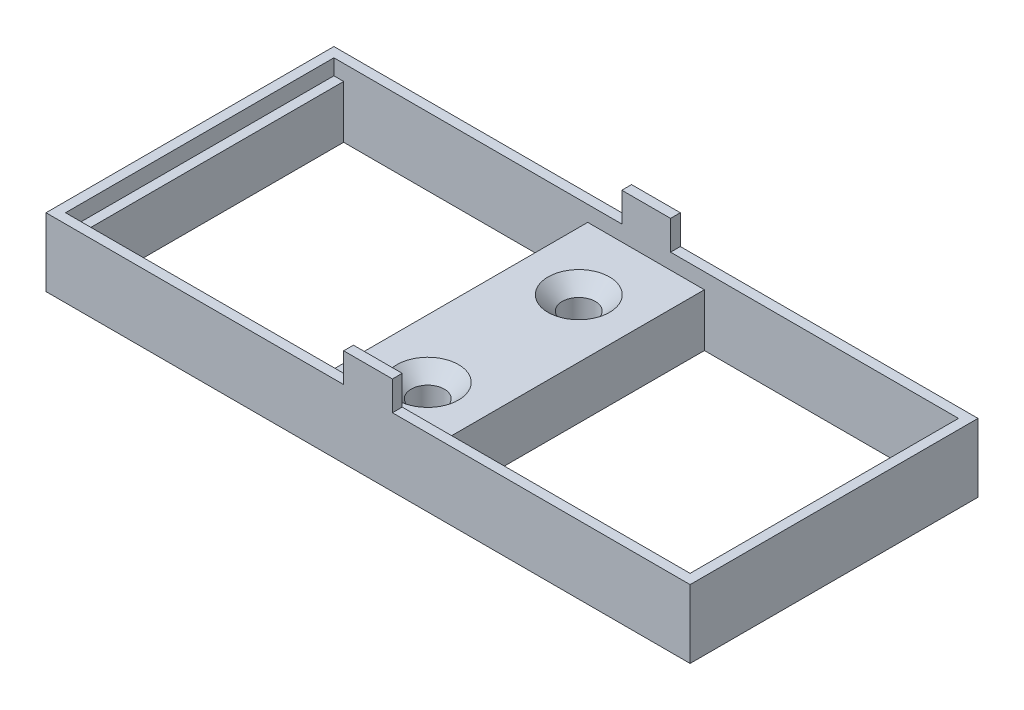
from build123d import *

# Parameters (mm, degrees)
SKETCH1_W                                           = 66
SKETCH1_H                                           = 29.5
BOSS_EXTRUDE1_DEPTH                                 = 7
SKETCH18_W                                          = 5
SKETCH18_H                                          = 1
BOSS_EXTRUDE3_DEPTH                                 = 3
SKETCH2_W                                           = 64
SKETCH2_H                                           = 27.5
CUT_EXTRUDE1_DEPTH                                  = 1.6
SKETCH19_W                                          = 25.008900438
SKETCH19_H                                          = 27.5
SKETCH19_W_2                                        = 25.033550957
CUT_EXTRUDE3_DEPTH                                  = 10
CSK_FOR_M3_COUNTERSUNK_FLAT_HEAD_SCREW2_D           = 3.4
CSK_FOR_M3_COUNTERSUNK_FLAT_HEAD_SCREW2_CSINK_D     = 6.3
CSK_FOR_M3_COUNTERSUNK_FLAT_HEAD_SCREW2_CSINK_ANGLE = 90


with BuildPart() as part:
    # Sketch1 → Boss-Extrude1 (new body)
    with BuildSketch(Plane(origin=(0, 0, 0), x_dir=(1, 0, 0), z_dir=(0, 1, 0))):
        with Locations((33, -14.75)):
            Rectangle(SKETCH1_W, SKETCH1_H)
    extrude(amount=BOSS_EXTRUDE1_DEPTH)

    # Sketch18 → Boss-Extrude3 (add)
    with BuildSketch(Plane(origin=(0, 7, 0), x_dir=(1, 0, 0), z_dir=(0, 1, 0))):
        with Locations((33, -0.5)):
            Rectangle(SKETCH18_W, SKETCH18_H)
        with Locations((33, -29)):
            Rectangle(SKETCH18_W, SKETCH18_H)
    extrude(amount=BOSS_EXTRUDE3_DEPTH)

    # Sketch2 → Cut-Extrude1 (cut)
    with BuildSketch(Plane(origin=(0, 7, 0), x_dir=(1, 0, 0), z_dir=(0, 1, 0))):
        with Locations((33, -14.75)):
            Rectangle(SKETCH2_W, SKETCH2_H)
    extrude(amount=-CUT_EXTRUDE1_DEPTH, mode=Mode.SUBTRACT)

    # Sketch19 → Cut-Extrude3 (cut)
    with BuildSketch(Plane(origin=(0, 5.4, 0), x_dir=(1, 0, 0), z_dir=(0, 1, 0))):
        with Locations((14.504450219, -14.75)):
            Rectangle(SKETCH19_W, SKETCH19_H)
        with Locations((51.483224522, -14.75)):
            Rectangle(SKETCH19_W_2, SKETCH19_H)
    extrude(amount=-CUT_EXTRUDE3_DEPTH, mode=Mode.SUBTRACT)

    # CSK for M3 Countersunk Flat Head Screw2 (through all)
    with Locations(Plane(origin=(32.966449043, 5.4, 7.875), x_dir=(0, 0, 1), z_dir=(0, 1, 0))):
        with Locations((0, 0), (15.515633601, 0.042451395)):
            CounterSinkHole(CSK_FOR_M3_COUNTERSUNK_FLAT_HEAD_SCREW2_D / 2, CSK_FOR_M3_COUNTERSUNK_FLAT_HEAD_SCREW2_CSINK_D / 2, counter_sink_angle=CSK_FOR_M3_COUNTERSUNK_FLAT_HEAD_SCREW2_CSINK_ANGLE)


solid = part.part
